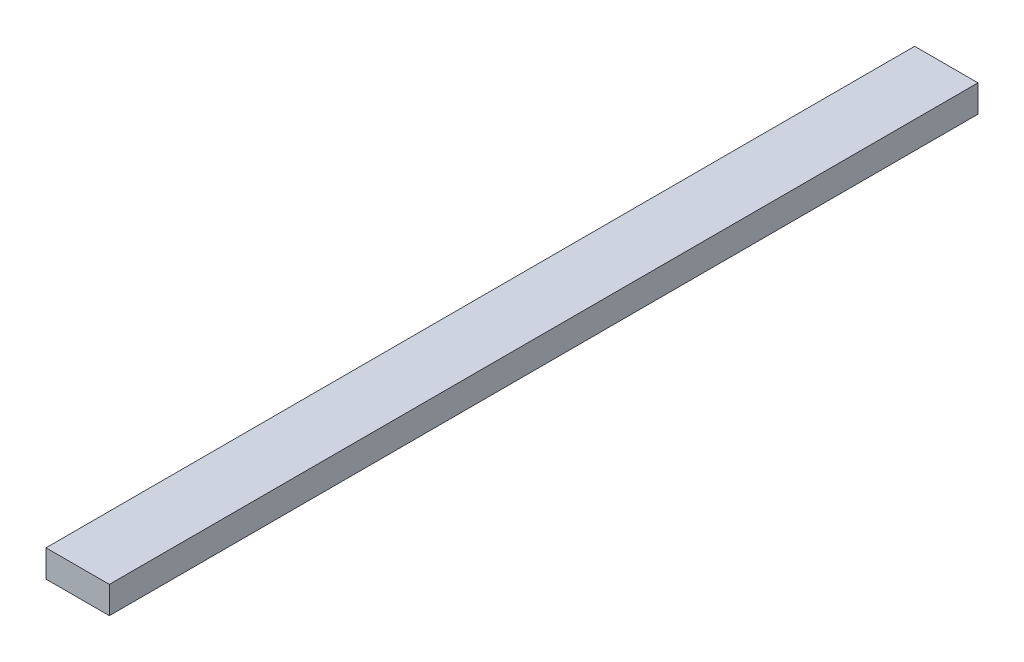
from build123d import *

# Parameters (mm, degrees)
SKETCH1_W           = 88.9
SKETCH1_H           = 38.1
BOSS_EXTRUDE1_DEPTH = 1219.2


with BuildPart() as part:
    # Sketch1 → Boss-Extrude1 (new body)
    with BuildSketch(Plane.XY):
        with Locations((18.332052689, 10.249349204)):
            Rectangle(SKETCH1_W, SKETCH1_H)
    extrude(amount=BOSS_EXTRUDE1_DEPTH)


solid = part.part
